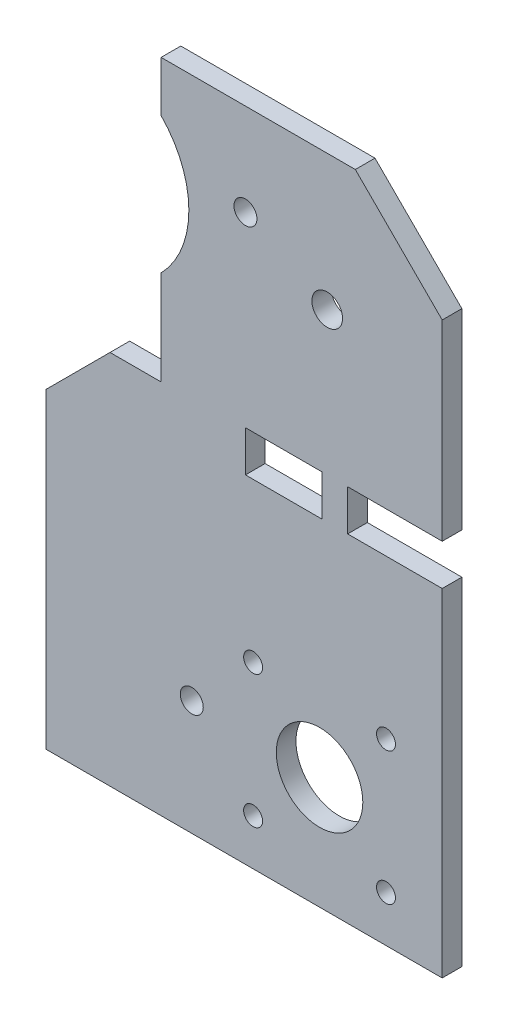
from build123d import *

# Parameters (mm, degrees)
SKETCH1_W            = 155
SKETCH1_H            = 257
BOSS_EXTRUDE1_DEPTH  = 7.7
CHAMFER1_SIZE        = 34
SKETCH2_R            = 4.5
SKETCH2_W            = 37
SKETCH2_H            = 16
CUT_EXTRUDE1_DEPTH   = 10
SKETCH3_R            = 38.109899267
CUT_EXTRUDE2_DEPTH   = 10
CUT_EXTRUDE3_DEPTH   = 10
SKETCH5_R            = 16.935062279
CUT_EXTRUDE4_DEPTH   = 10
SKETCH6_R            = 3.705491154
CUT_EXTRUDE5_DEPTH   = 10
LPATTERN1_COUNT      = 2
LPATTERN1_PITCH      = 52
LPATTERN1_COUNT_DIR2 = 2
LPATTERN1_PITCH_DIR2 = 52
SKETCH7_R            = 6
CUT_EXTRUDE6_DEPTH   = 10
SKETCH8_W            = 30
SKETCH8_H            = 16
CUT_EXTRUDE7_DEPTH   = 10


with BuildPart() as part:
    # Sketch1 → Boss-Extrude1 (new body)
    with BuildSketch(Plane.XY):
        with Locations((64.176783005, -115.237481032)):
            Rectangle(SKETCH1_W, SKETCH1_H)
    extrude(amount=BOSS_EXTRUDE1_DEPTH)

    # Chamfer1
    chamfer1_edges = [part.edges().sort_by_distance(p)[0] for p in [
        (141.676783005, 13.262518968, 3.85),
    ]]
    chamfer(chamfer1_edges, length=CHAMFER1_SIZE)

    # Sketch2 → Cut-Extrude1 (cut)
    with BuildSketch(Plane.XY.offset(7.7)):
        with Locations((64.676783005, -22.737481032)):
            Circle(SKETCH2_R)
        with Locations((43.676783005, -198.737481032)):
            Circle(SKETCH2_R)
        with Locations((123.176783005, -103.737481032)):
            Rectangle(SKETCH2_W, SKETCH2_H)
    extrude(amount=-CUT_EXTRUDE1_DEPTH, mode=Mode.SUBTRACT)

    # Sketch3 → Cut-Extrude2 (cut)
    with BuildSketch(Plane.XY.offset(7.7)):
        with Locations((4.429117296, -33.119350325)):
            Circle(SKETCH3_R)
    extrude(amount=-CUT_EXTRUDE2_DEPTH, mode=Mode.SUBTRACT)

    # Sketch4 → Cut-Extrude3 (cut)
    with BuildSketch(Plane.XY.offset(7.7)):
        Polygon((31.676783005, 13.262518968), (31.676783005, -96.737481032), (11.676783005, -96.737481032), (-13.323216995, -121.737481032), (-67.69781948, -122.43585218), (-69.553853122, 22.073398829), (23.898503121, 29.809405578), align=None)
    extrude(amount=-CUT_EXTRUDE3_DEPTH, mode=Mode.SUBTRACT)

    # Sketch5 → Cut-Extrude4 (cut)
    with BuildSketch(Plane.XY.offset(7.7)):
        with Locations((93.676783005, -199.737481032)):
            Circle(SKETCH5_R)
    extrude(amount=-CUT_EXTRUDE4_DEPTH, mode=Mode.SUBTRACT)

    # Sketch6 → Cut-Extrude5 (cut)
    with BuildSketch(Plane.XY.offset(7.7)):
        with Locations((67.676783005, -225.737481032)):
            Circle(SKETCH6_R)
    cut_extrude5 = extrude(amount=-CUT_EXTRUDE5_DEPTH, mode=Mode.SUBTRACT)

    # LPattern1: Cut-Extrude5 2 × 2
    with Locations(*[(j * LPATTERN1_PITCH_DIR2, i * LPATTERN1_PITCH, 0) for i in range(LPATTERN1_COUNT) for j in range(LPATTERN1_COUNT_DIR2) if (i, j) != (0, 0)]):
        add(cut_extrude5, mode=Mode.SUBTRACT)

    # Sketch7 → Cut-Extrude6 (cut)
    with BuildSketch(Plane.XY.offset(7.7)):
        with Locations((96.676783005, -39.737481032)):
            Circle(SKETCH7_R)
    extrude(amount=-CUT_EXTRUDE6_DEPTH, mode=Mode.SUBTRACT)

    # Sketch8 → Cut-Extrude7 (cut)
    with BuildSketch(Plane.XY.offset(7.7)):
        with Locations((79.676783005, -103.737481032)):
            Rectangle(SKETCH8_W, SKETCH8_H)
    extrude(amount=-CUT_EXTRUDE7_DEPTH, mode=Mode.SUBTRACT)


solid = part.part
